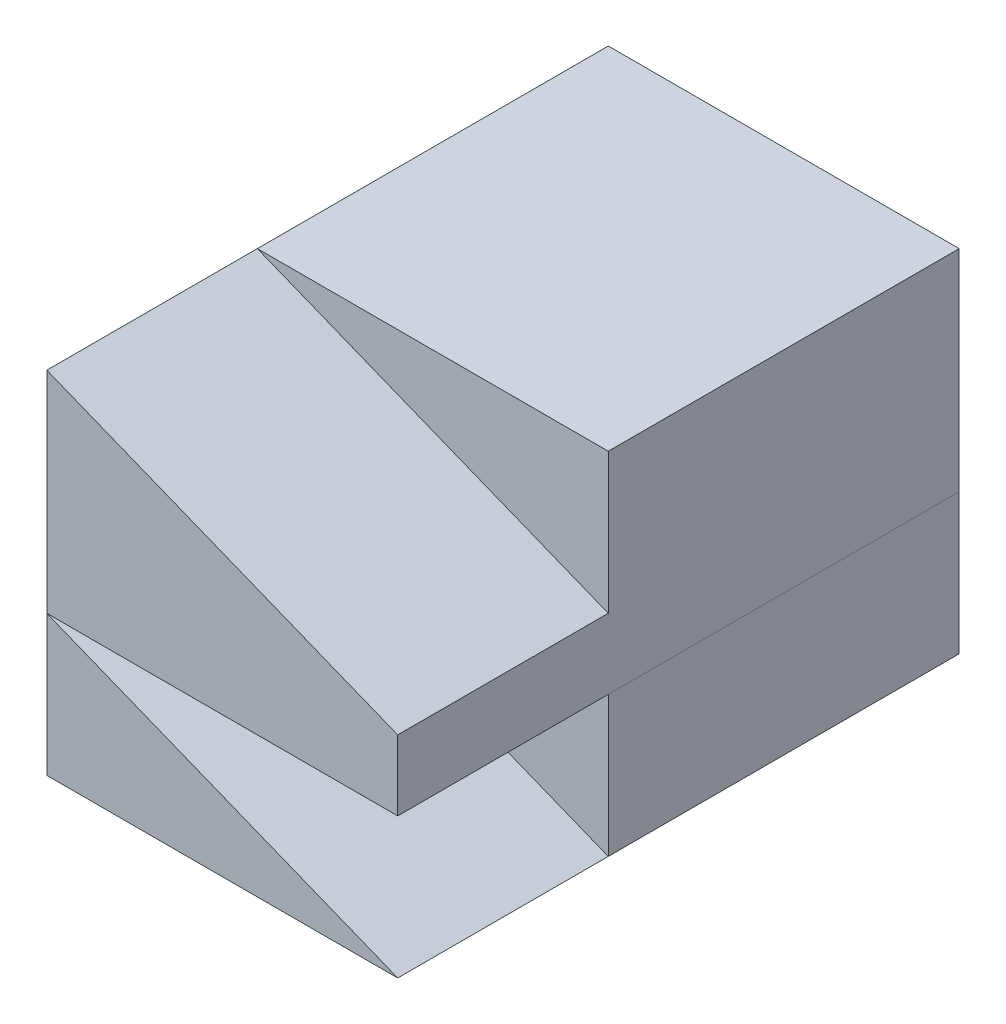
from build123d import *

# Parameters (mm, degrees)
BOSS_EXTRUDE1_DEPTH  = 15
SKETCH2_W            = 15
SKETCH2_H            = 5
BOSS_EXTRUDE2_DEPTH  = 25
BOSS_EXTRUDE3_DEPTH  = 15
BOSS_EXTRUDE27_DEPTH = 25
SKETCH12_W           = 25
SKETCH12_H           = 10
BOSS_EXTRUDE36_DEPTH = 25


with BuildPart() as part:
    # Sketch1 → Boss-Extrude1 (new body)
    with BuildSketch(Plane.XY):
        Polygon((-25, 10), (-25, 0), (0, 0), align=None)
    extrude(amount=BOSS_EXTRUDE1_DEPTH)



with BuildPart() as body_2:
    # Sketch2 → Boss-Extrude2 (new body)
    with BuildSketch(Plane.ZY.offset(25)):
        with Locations((7.5, 12.5)):
            Rectangle(SKETCH2_W, SKETCH2_H)
    extrude(amount=-BOSS_EXTRUDE2_DEPTH)

    # Sketch3 → Boss-Extrude3 (add)
    with BuildSketch(Plane.XY.offset(15)):
        Polygon((-25, 15), (-25, 25), (0, 15), align=None)
    extrude(amount=-BOSS_EXTRUDE3_DEPTH)


with BuildPart() as part_1:
    add(part.part)

    add(body_2.part)  # Boss-Extrude27 merges body 2
    # Sketch4 → Boss-Extrude27 (add)
    with BuildSketch(Plane(origin=(0, 0, 0), x_dir=(-1, 0, 0), z_dir=(0, 0, -1))):
        Polygon((0, 10), (25, 10), (25, 25), (0, 15), align=None)
        Polygon((0, 25), (0, 15), (25, 25), align=None)
        Polygon((25, 0), (25, 10), (0, 0), align=None)
    extrude(amount=BOSS_EXTRUDE27_DEPTH)


with BuildPart() as body_2_2:
    # Sketch12 → Boss-Extrude36 (new body)
    with BuildSketch(Plane(origin=(0, 0, 0), x_dir=(0, 0, -1), z_dir=(1, 0, 0))):
        with Locations((12.5, 5)):
            Rectangle(SKETCH12_W, SKETCH12_H)
    extrude(amount=-BOSS_EXTRUDE36_DEPTH)


solid = Compound([part_1.part, body_2_2.part])
